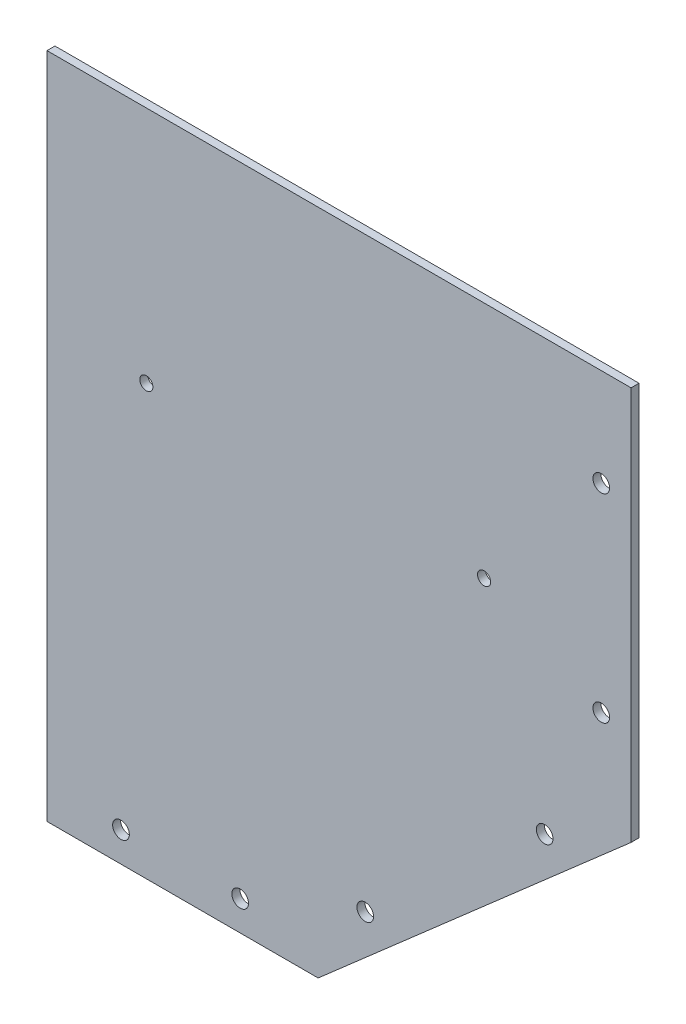
from build123d import *

# Parameters (mm, degrees)
SKETCH_1_R          = 2.1
EXTRUDE_1_DEPTH     = 2
SKETCH_3_R          = 1
CUT_EXTRUDE_1_DEPTH = 10
M4X0_7_1_D          = 3.3
M4X0_7_1_DEPTH      = 11.5
M4X0_7_1_TIP        = 0.991420021


with BuildPart() as part:
    # ｽｹｯﾁ1 → ﾎﾞｽ - 押し出し1 (new body)
    with BuildSketch(Plane.XY):
        Polygon((0, 0), (68.24, 0), (146.992249894, 68.918108191), (146.992249894, 168.01), (0, 168.01), align=None)
        with Locations((18.62, 7.5)):
            Circle(SKETCH_1_R, mode=Mode.SUBTRACT)
        with Locations((48.62, 7.5)):
            Circle(SKETCH_1_R, mode=Mode.SUBTRACT)
        with Locations((139.492249894, 93.468108191)):
            Circle(SKETCH_1_R, mode=Mode.SUBTRACT)
        with Locations((139.492249894, 143.468108191)):
            Circle(SKETCH_1_R, mode=Mode.SUBTRACT)
        with Locations((125.249072144, 59.856479125)):
            Circle(SKETCH_1_R, mode=Mode.SUBTRACT)
        with Locations((80.097280518, 20.342991391)):
            Circle(SKETCH_1_R, mode=Mode.SUBTRACT)
    extrude(amount=EXTRUDE_1_DEPTH)

    # ｽｹｯﾁ3 → ｶｯﾄ - 押し出し1 (cut)
    with BuildSketch(Plane.XY.offset(2)):
        with Locations((25, 108.01)):
            Circle(SKETCH_3_R)
        with Locations((110, 108.01)):
            Circle(SKETCH_3_R)
    extrude(amount=-CUT_EXTRUDE_1_DEPTH, mode=Mode.SUBTRACT)

    # M4x0.7 ねじ穴1
    with Locations(Plane(origin=(25, 108.01, 2), x_dir=(1, 0, 0), z_dir=(0, 0, 1))):
        with Locations((0, 0), (85, 0)):
            Hole(M4X0_7_1_D / 2, depth=M4X0_7_1_DEPTH)
            with Locations((0, 0, -(M4X0_7_1_DEPTH + M4X0_7_1_TIP / 2))):  # 118° drill point
                Cone(0, M4X0_7_1_D / 2, M4X0_7_1_TIP, mode=Mode.SUBTRACT)


solid = part.part
